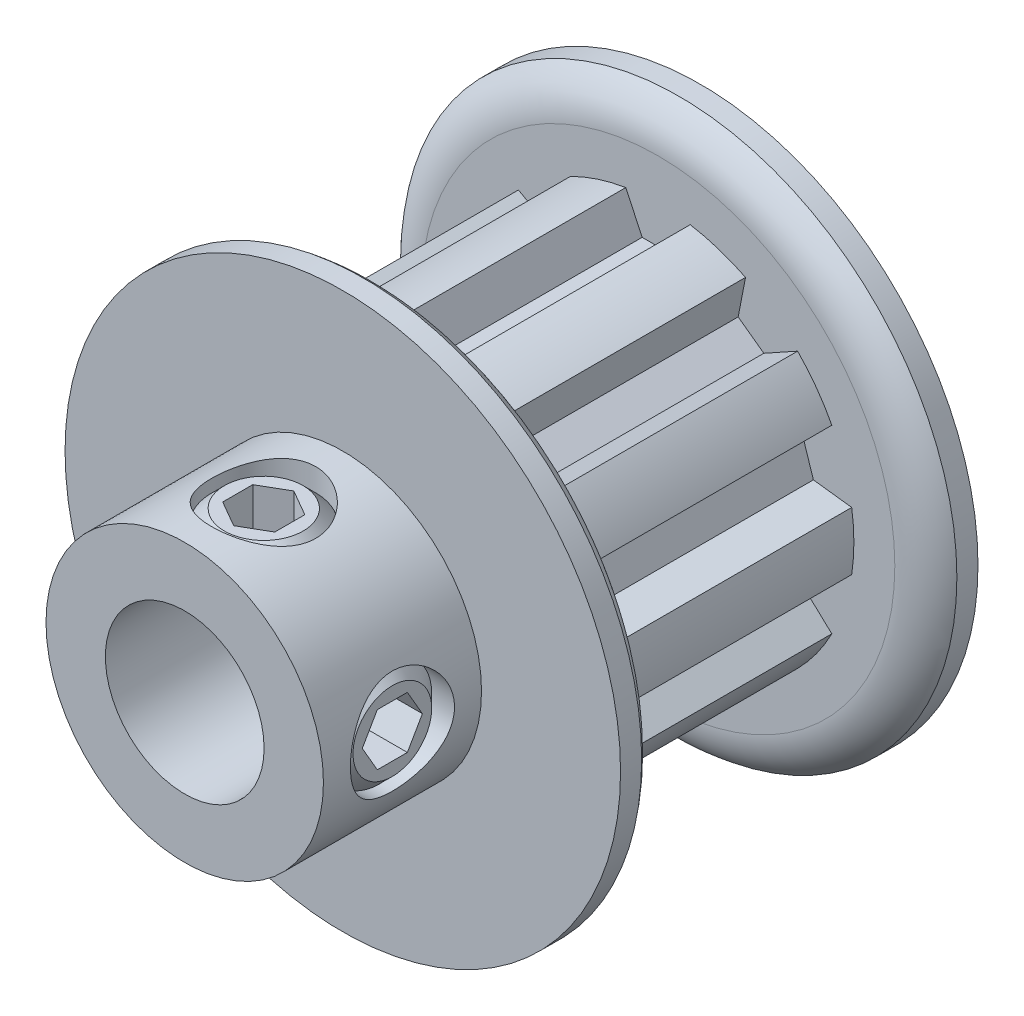
from build123d import *

# Parameters (mm, degrees)
CUT_EXTRUDE1_START = 2.2987
CUT_EXTRUDE1_DEPTH = 10.922
CIRPATTERN1_COUNT  = 10
SKETCH4_R          = 2.0828
CUT_EXTRUDE2_DEPTH = 19.796832346
CUT_EXTRUDE3_DEPTH = 1.5621
CIRPATTERN2_COUNT  = 2
CIRPATTERN2_ANGLE  = 90


with BuildPart() as part:
    # Sketch2 → Revolve1 (revolve)
    with BuildSketch(Plane(origin=(0, 0, 0), x_dir=(0, 0, -1), z_dir=(1, 0, 0)), mode=Mode.PRIVATE) as revolve1_sk:
        with BuildLine():
            Line((-10.3124, 3.175), (10.3124, 3.175))
            Line((10.3124, 3.175), (10.3124, 11.1125))
            Line((10.3124, 11.1125), (9.46785, 11.1125))
            ThreePointArc((9.46785, 11.1125), (8.846862309, 10.395787163), (8.6233, 9.4742))
            Line((8.6233, 9.4742), (8.6233, 7.8359))
            Line((8.6233, 7.8359), (-2.2987, 7.8359))
            Line((-2.2987, 7.8359), (-2.2987, 9.4742))
            ThreePointArc((-2.2987, 9.4742), (-2.522262309, 10.395787163), (-3.14325, 11.1125))
            Line((-3.14325, 11.1125), (-3.9878, 11.1125))
            Line((-3.9878, 11.1125), (-3.9878, 5.5499))
            Line((-3.9878, 5.5499), (-10.3124, 5.5499))
            Line((-10.3124, 5.5499), (-10.3124, 3.175))
        make_face()
    revolve(revolve1_sk.sketch.rotate(Axis((0, 0, 10.3124), (0, 0, -1)), 90), axis=Axis((0, 0, 10.3124), (0, 0, -1)))

    # Sketch3 → Cut-Extrude1 (cut)
    with BuildSketch(Plane.XY.offset(CUT_EXTRUDE1_START)):
        with BuildLine():
            Line((-0.635, 6.329348022), (0.635, 6.329348022))
            Line((0.635, 6.329348022), (1.287830721, 7.729348022))
            ThreePointArc((1.287830721, 7.729348022), (0, 7.8359), (-1.287830721, 7.729348022))
            Line((-1.287830721, 7.729348022), (-0.635, 6.329348022))
        make_face()
    cut_extrude1 = extrude(amount=-CUT_EXTRUDE1_DEPTH, mode=Mode.SUBTRACT)

    # CirPattern1: Cut-Extrude1 ×10 about axis
    cirpattern1_axis = Axis((0, 0, 0), (0, 0, 1))
    for i in range(1, CIRPATTERN1_COUNT):
        add(cut_extrude1.rotate(cirpattern1_axis, i * 360 / CIRPATTERN1_COUNT), mode=Mode.SUBTRACT)

    # Sketch4 → Cut-Extrude2 (cut, through all)
    with BuildSketch(Plane(origin=(0, 0, 0), x_dir=(1, 0, 0), z_dir=(0, 1, 0))):
        with Locations(Location((0, -7.1501, 0), (0, 0, 90))):
            Circle(SKETCH4_R)
    cut_extrude2 = extrude(amount=CUT_EXTRUDE2_DEPTH, mode=Mode.SUBTRACT)

    # Sketch5 → Revolve2 (revolve)
    with BuildSketch(Plane.XY.offset(7.1501), mode=Mode.PRIVATE) as revolve2_sk:
        Polygon((1.5748, 5.144252538), (2.0828, 4.636252538), (2.0828, 3.81), (1.4478, 3.175), (0, 3.175), (0, 5.144252538), align=None)
    revolve2 = revolve(revolve2_sk.sketch.rotate(Axis((0, 0, 7.1501), (0, 1, 0)), 90), axis=Axis((0, 0, 7.1501), (0, 1, 0)))

    # Sketch6 → Cut-Extrude3 (cut)
    with BuildSketch(Plane(origin=(0, 5.144252538, 0), x_dir=(1, 0, 0), z_dir=(0, 1, 0))):
        Polygon((0, -5.947594859), (-1.0414, -6.54884743), (-1.0414, -7.75135257), (0, -8.352605141), (1.0414, -7.75135257), (1.0414, -6.54884743), align=None)
    cut_extrude3 = extrude(amount=-CUT_EXTRUDE3_DEPTH, mode=Mode.SUBTRACT)

    # CirPattern2: Cut-Extrude2, Revolve2, Cut-Extrude3 ×2 about axis
    cirpattern2_axis = Axis((0, 0, 0), (0, 0, -1))
    add([cut_extrude2.rotate(cirpattern2_axis, i * CIRPATTERN2_ANGLE / (CIRPATTERN2_COUNT - 1)) for i in range(1, CIRPATTERN2_COUNT)], mode=Mode.SUBTRACT)
    add([revolve2.rotate(cirpattern2_axis, i * CIRPATTERN2_ANGLE / (CIRPATTERN2_COUNT - 1)) for i in range(1, CIRPATTERN2_COUNT)])
    add([cut_extrude3.rotate(cirpattern2_axis, i * CIRPATTERN2_ANGLE / (CIRPATTERN2_COUNT - 1)) for i in range(1, CIRPATTERN2_COUNT)], mode=Mode.SUBTRACT)


solid = part.part
